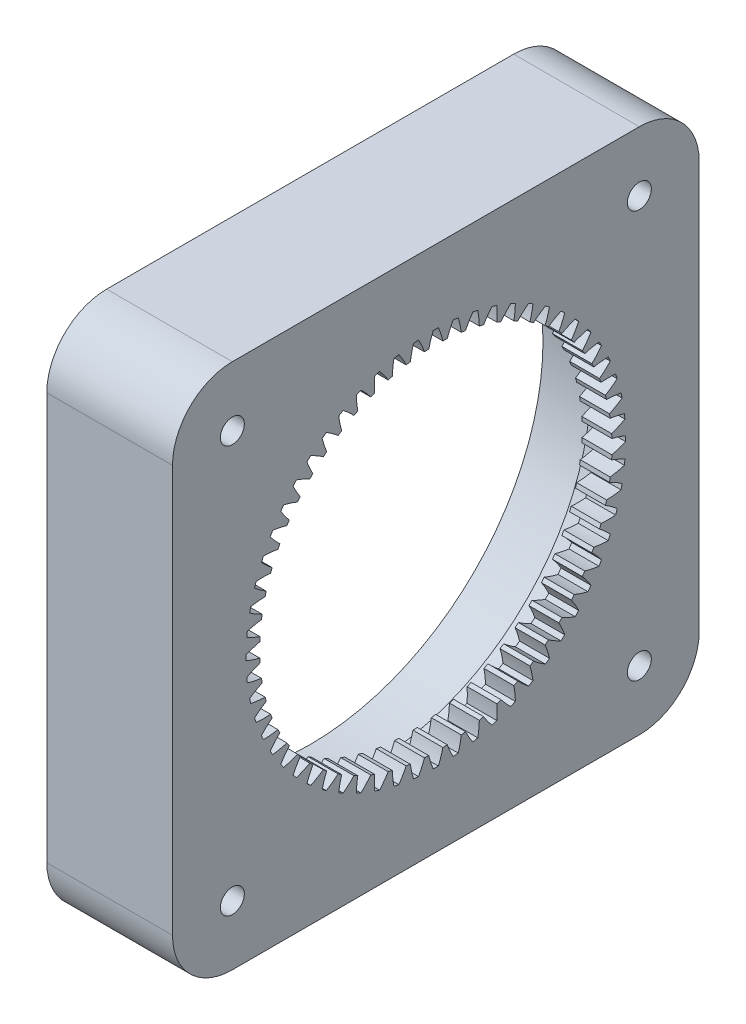
from build123d import *

# Parameters (mm, degrees)
BASPROSKE_W              = 5
BASPROSKE_H              = 14.565
TOOTHCUT_DEPTH           = 63.42595614
TEETHCUTS_COUNT          = 60
SKETCH4_R                = 44
SKETCH4_R_2              = 38.9
BOSS_EXTRUDE3_DEPTH      = 16
BOSS_EXTRUDE5_DEPTH      = 21
FILLET1_R                = 10
CIRPATTERN2_COUNT        = 4
FILLET1_OF_CIRPATTERN2_R = 10
SKETCH14_R               = 38.9
SKETCH14_R_2             = 36.9
BOSS_EXTRUDE7_DEPTH      = 6
SKETCH15_R               = 2
CUT_EXTRUDE1_DEPTH       = 66.673434507


with BuildPart() as part:
    # BasProSke → Base-Revolve (revolve)
    with BuildSketch(Plane(origin=(0, 0, 0), x_dir=(1, 0, 0), z_dir=(0, 1, 0)), mode=Mode.PRIVATE) as base_revolve_sk:
        with Locations((2.5, 36.7175)):
            Rectangle(BASPROSKE_W, BASPROSKE_H)
    revolve(base_revolve_sk.sketch.rotate(Axis((-10, 0, 0), (1, 0, 0)), 180), axis=Axis((-10, 0, 0), (1, 0, 0)))

    # TooCutSke → ToothCut (cut, through all)
    with BuildSketch(Plane(origin=(0, 0, 0), x_dir=(0, 0, -1), z_dir=(1, 0, 0))):
        with BuildLine():
            ThreePointArc((1.182891501, 29.385801671), (0.850504168, 30.566654642), (0.424126801, 31.71691436))
            ThreePointArc((0.424126801, 31.71691436), (0, 31.71975), (-0.424126801, 31.71691436))
            ThreePointArc((-0.424126801, 31.71691436), (-0.850504168, 30.566654642), (-1.182891501, 29.385801671))
            ThreePointArc((-1.182891501, 29.385801671), (0, 29.4096), (1.182891501, 29.385801671))
        make_face()
    toothcut = extrude(amount=TOOTHCUT_DEPTH, mode=Mode.SUBTRACT)

    # TeethCuts: ToothCut ×60 about axis
    teethcuts_axis = Axis((0, 0, 0), (1, 0, 0))
    for i in range(1, TEETHCUTS_COUNT):
        add(toothcut.rotate(teethcuts_axis, i * 360 / TEETHCUTS_COUNT), mode=Mode.SUBTRACT)

    # Sketch4 → Boss-Extrude3 (add)
    with BuildSketch(Plane.ZY):
        Circle(SKETCH4_R)
        Circle(SKETCH4_R_2, mode=Mode.SUBTRACT)
    extrude(amount=BOSS_EXTRUDE3_DEPTH)

    # Sketch7 → Boss-Extrude5 (add)
    with BuildSketch(Plane(origin=(5, 0, 0), x_dir=(0, 0, -1), z_dir=(1, 0, 0))):
        with BuildLine():
            Line((0, 44), (44, 44))
            Line((44, 44), (44, 0))
            ThreePointArc((44, 0), (31.112698372, 31.112698372), (0, 44))
        make_face()
    boss_extrude5 = extrude(amount=-BOSS_EXTRUDE5_DEPTH)

    # Fillet1
    fillet1_edges = [part.edges().sort_by_distance(p)[0] for p in [
        (-5.5, 44, -44),
    ]]
    fillet(fillet1_edges, radius=FILLET1_R)

    # CirPattern2: Boss-Extrude5 ×4 about axis
    cirpattern2_axis = Axis((0, 0, 0), (1, 0, 0))
    for i in range(1, CIRPATTERN2_COUNT):
        add(boss_extrude5.rotate(cirpattern2_axis, i * 360 / CIRPATTERN2_COUNT))

    # Fillet1 of CirPattern2
    fillet1_of_cirpattern2_edges = [part.edges().sort_by_distance(p)[0] for p in [
        (-5.5, 44, 44),
        (-5.5, -44, 44),
        (-5.5, -44, -44),
    ]]
    fillet(fillet1_of_cirpattern2_edges, radius=FILLET1_OF_CIRPATTERN2_R)

    # Sketch14 → Boss-Extrude7 (add)
    with BuildSketch(Plane.ZY):
        Circle(SKETCH14_R)
        Circle(SKETCH14_R_2, mode=Mode.SUBTRACT)
    extrude(amount=BOSS_EXTRUDE7_DEPTH)

    # Sketch15 → Cut-Extrude1 (cut, through all)
    with BuildSketch(Plane.ZY.offset(16)):
        with Locations((-34, 34)):
            Circle(SKETCH15_R)
        with Locations((-34, -34)):
            Circle(SKETCH15_R)
        with Locations((34, -34)):
            Circle(SKETCH15_R)
        with Locations((34, 34)):
            Circle(SKETCH15_R)
    extrude(amount=-CUT_EXTRUDE1_DEPTH, mode=Mode.SUBTRACT)


solid = part.part
